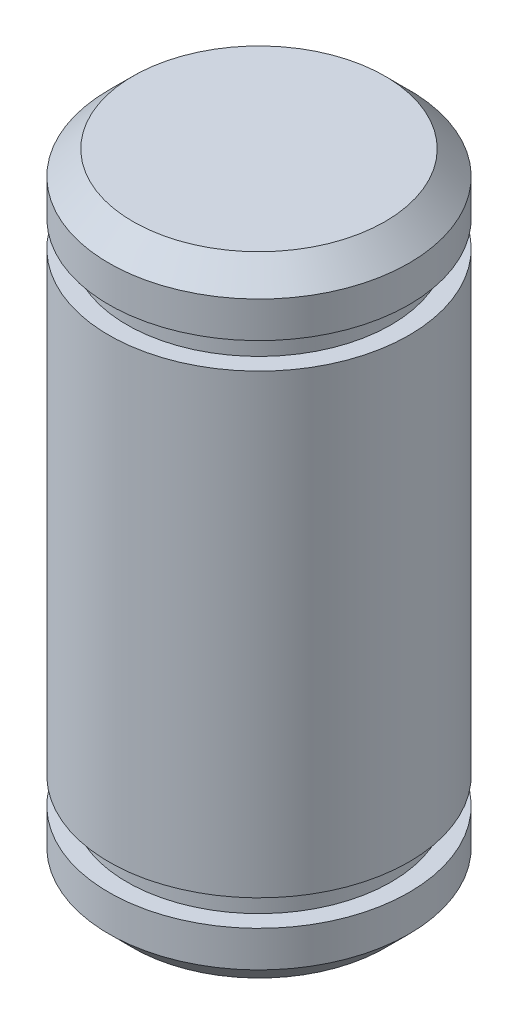
from build123d import *

# Parameters (mm, degrees)
CHAMFER1_SIZE = 0.508


with BuildPart() as part:
    # Sketch1 → Revolve1 (revolve)
    with BuildSketch(Plane.XY):
        Polygon((-3.175, 4.826), (-3.175, -4.826), (-2.794, -4.826), (-2.794, -5.3848), (-3.175, -5.3848), (-3.175, -6.6548), (0, -6.6548), (0, 6.6548), (-3.175, 6.6548), (-3.175, 5.3848), (-2.794, 5.3848), (-2.794, 4.826), align=None)
    revolve(axis=Axis((0, 6.6548, 0), (0, 1, 0)))

    # Chamfer1
    chamfer1_edges = [part.edges().sort_by_distance(p)[0] for p in [
        (3.175, -6.6548, 0),
        (3.175, 6.6548, 0),
    ]]
    chamfer(chamfer1_edges, length=CHAMFER1_SIZE)


solid = part.part
